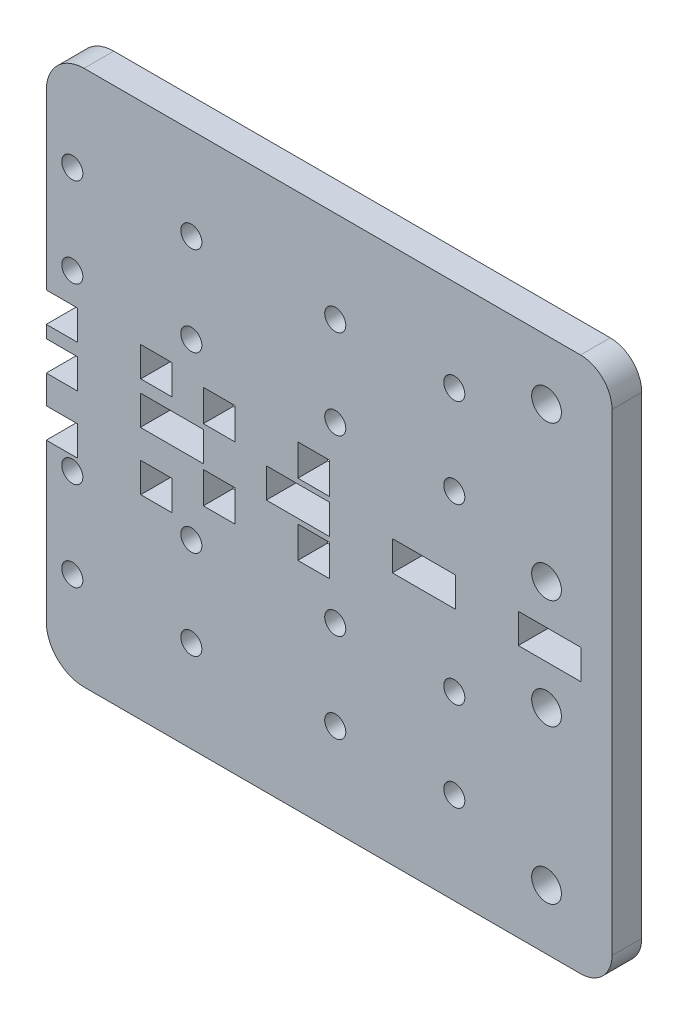
from build123d import *

# Parameters (mm, degrees)
SKETCH1_R           = 2.125
SKETCH1_R_2         = 3
SKETCH1_W           = 6.35
SKETCH1_H           = 6
SKETCH1_W_2         = 12.7
SKETCH1_H_2         = 5.9944
SKETCH1_H_3         = 6.35
BOSS_EXTRUDE1_DEPTH = 5.9944


with BuildPart() as part:
    # Sketch1 → Boss-Extrude1 (new body)
    with BuildSketch(Plane(origin=(0, 0, 0), x_dir=(-1, 0, 0), z_dir=(0, 0, 1))):
        with BuildLine():
            Line((70.702589937, 1.66614002), (72.098749997, 1.66614002))
            Line((72.098749997, 1.66614002), (72.098749997, 7.383354962))
            Line((72.098749997, 7.383354962), (65.748749997, 7.383354962))
            Line((65.748749997, 7.383354962), (65.748749997, 13.383354962))
            Line((65.748749997, 13.383354962), (72.098749997, 13.383354962))
            Line((72.098749997, 13.383354962), (72.098749997, 45.072109768))
            ThreePointArc((72.098749997, 45.072109768), (69.866903669, 50.460263441), (64.478749997, 52.692109768))
            Line((64.478749997, 52.692109768), (45.302589937, 52.692109768))
            Line((45.302589937, 52.692109768), (19.902589937, 52.692109768))
            Line((19.902589937, 52.692109768), (-35.623445702, 52.692109768))
            ThreePointArc((-35.623445702, 52.692109768), (-40.113573763, 50.832237829), (-41.973445702, 46.342109768))
            Line((-41.973445702, 46.342109768), (-41.973445702, -49.004229729))
            ThreePointArc((-41.973445702, -49.004229729), (-40.113573763, -53.494357789), (-35.623445702, -55.354229729))
            Line((-35.623445702, -55.354229729), (19.902589937, -55.354229729))
            Line((19.902589937, -55.354229729), (45.302589937, -55.354229729))
            Line((45.302589937, -55.354229729), (64.478749997, -55.354229729))
            ThreePointArc((64.478749997, -55.354229729), (69.866903669, -53.122383402), (72.098749997, -47.734229729))
            Line((72.098749997, -47.734229729), (72.098749997, -12.840645038))
            Line((72.098749997, -12.840645038), (65.748749997, -12.840645038))
            Line((65.748749997, -12.840645038), (65.748749997, -6.840645038))
            Line((65.748749997, -6.840645038), (72.098749997, -6.840645038))
            Line((72.098749997, -6.840645038), (72.098749997, -4.32825998))
            Line((72.098749997, -4.32825998), (70.702589937, -4.32825998))
            Line((70.702589937, -4.32825998), (65.829579937, -4.32825998))
            Line((65.829579937, -4.32825998), (65.829579937, 1.66614002))
            Line((65.829579937, 1.66614002), (70.702589937, 1.66614002))
        make_face()
        with Locations((-10.170420063, -18.840645038)):
            Circle(SKETCH1_R, mode=Mode.SUBTRACT)
        with Locations((66.848749997, -36.840645038)):
            Circle(SKETCH1_R, mode=Mode.SUBTRACT)
        with Locations((42.848749997, -18.840645038)):
            Circle(SKETCH1_R, mode=Mode.SUBTRACT)
        with Locations((-28.770420063, -43.34064498)):
            Circle(SKETCH1_R_2, mode=Mode.SUBTRACT)
        with Locations((-28.770420063, -12.34064498)):
            Circle(SKETCH1_R_2, mode=Mode.SUBTRACT)
        with Locations((13.829579937, -18.840645038)):
            Circle(SKETCH1_R, mode=Mode.SUBTRACT)
        with Locations((42.848749997, -36.840645038)):
            Circle(SKETCH1_R, mode=Mode.SUBTRACT)
        with Locations((-10.170420063, -36.840645038)):
            Circle(SKETCH1_R, mode=Mode.SUBTRACT)
        with Locations((66.848749997, -18.840645038)):
            Circle(SKETCH1_R, mode=Mode.SUBTRACT)
        with Locations((13.829579937, -36.840645038)):
            Circle(SKETCH1_R, mode=Mode.SUBTRACT)
        with Locations((-28.770420063, 9.67852502)):
            Circle(SKETCH1_R_2, mode=Mode.SUBTRACT)
        with Locations((-28.770420063, 40.67852502)):
            Circle(SKETCH1_R_2, mode=Mode.SUBTRACT)
        with Locations((-10.170420063, 34.178525078)):
            Circle(SKETCH1_R, mode=Mode.SUBTRACT)
        with Locations((13.829579937, 34.178525078)):
            Circle(SKETCH1_R, mode=Mode.SUBTRACT)
        with Locations((13.829579937, 16.178525078)):
            Circle(SKETCH1_R, mode=Mode.SUBTRACT)
        with Locations((-10.170420063, 16.178525078)):
            Circle(SKETCH1_R, mode=Mode.SUBTRACT)
        with Locations((42.848749997, 34.178525078)):
            Circle(SKETCH1_R, mode=Mode.SUBTRACT)
        with Locations((66.848749997, 34.178525078)):
            Circle(SKETCH1_R, mode=Mode.SUBTRACT)
        with Locations((66.848749997, 16.178525078)):
            Circle(SKETCH1_R, mode=Mode.SUBTRACT)
        with Locations((42.848749997, 16.178525078)):
            Circle(SKETCH1_R, mode=Mode.SUBTRACT)
        with Locations((49.873749997, 10.383354962)):
            Rectangle(SKETCH1_W, SKETCH1_H, mode=Mode.SUBTRACT)
        with Locations((-29.420420063, -1.33105998)):
            Rectangle(SKETCH1_W_2, SKETCH1_H_2, mode=Mode.SUBTRACT)
        with Locations((49.873749997, -9.840645038)):
            Rectangle(SKETCH1_W, SKETCH1_H, mode=Mode.SUBTRACT)
        with Locations((-4.020420063, -1.33105998)):
            Rectangle(SKETCH1_W_2, SKETCH1_H_2, mode=Mode.SUBTRACT)
        with Locations((21.379579937, -1.33105998)):
            Rectangle(SKETCH1_W_2, SKETCH1_H_2, mode=Mode.SUBTRACT)
        with Locations((46.779579937, -1.33105998)):
            Rectangle(SKETCH1_W_2, SKETCH1_H_2, mode=Mode.SUBTRACT)
        with Locations((18.204579937, 5.84394002)):
            Rectangle(SKETCH1_W, SKETCH1_H_3, mode=Mode.SUBTRACT)
        with Locations((37.254579937, -8.50605998)):
            Rectangle(SKETCH1_W, SKETCH1_H_3, mode=Mode.SUBTRACT)
        with Locations((18.204579937, -8.50605998)):
            Rectangle(SKETCH1_W, SKETCH1_H_3, mode=Mode.SUBTRACT)
        with Locations((37.254579937, 5.84394002)):
            Rectangle(SKETCH1_W, SKETCH1_H_3, mode=Mode.SUBTRACT)
    extrude(amount=BOSS_EXTRUDE1_DEPTH)


solid = part.part
